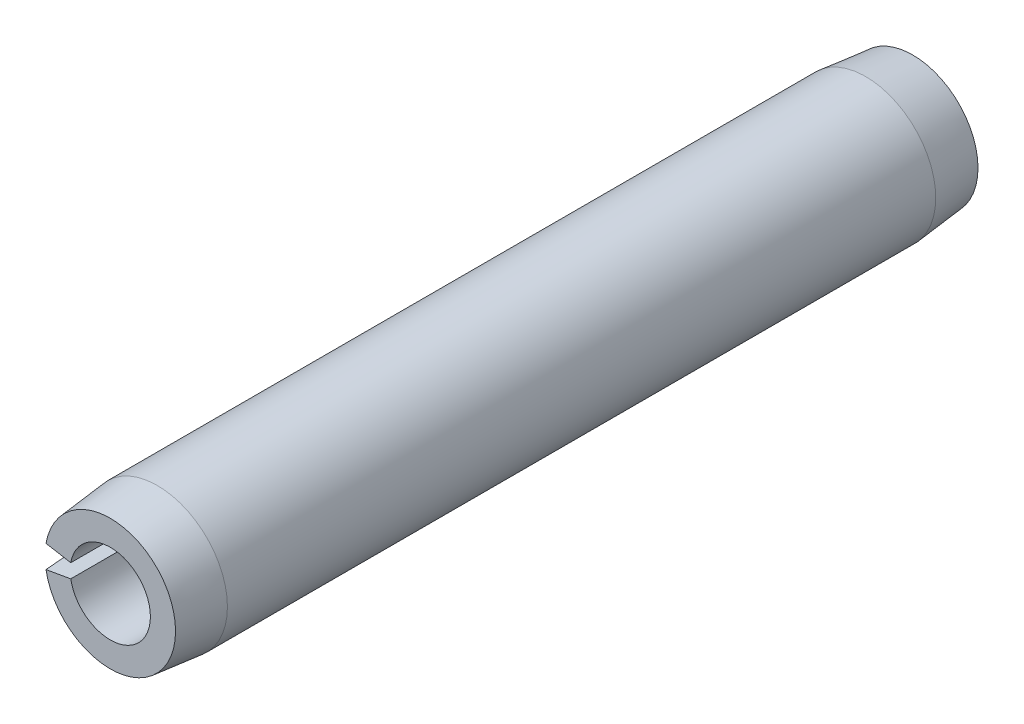
from build123d import *

# Parameters (mm, degrees)
EXTRUDE1_DEPTH = 9.525


with BuildPart() as part:
    # Sketch1 → Extrude1 (new body, symmetric)
    with BuildSketch(Plane.XY):
        with BuildLine():
            Line((-1.638424659, 0.288898473), (-0.938029385, 0.165399889))
            ThreePointArc((-0.938029385, 0.165399889), (0.9525, 0), (-0.938029385, -0.165399889))
            Line((-0.938029385, -0.165399889), (-1.638424659, -0.288898473))
            ThreePointArc((-1.638424659, -0.288898473), (1.6637, 0), (-1.638424659, 0.288898473))
        make_face()
    extrude(amount=EXTRUDE1_DEPTH, both=True)

    # Sketch2 → Cut-Revolve1 (revolve, cut)
    with BuildSketch(Plane(origin=(0, 0, 0), x_dir=(0, 0, -1), z_dir=(1, 0, 0))):
        Polygon((9.525, 1.6637), (9.525, 1.5494), (8.4074, 1.6637), align=None)
        Polygon((-8.4074, 1.6637), (-9.525, 1.6637), (-9.525, 1.5494), align=None)
    revolve(axis=Axis((0, 0, -9.525), (0, 0, 1)), mode=Mode.SUBTRACT)


solid = part.part
